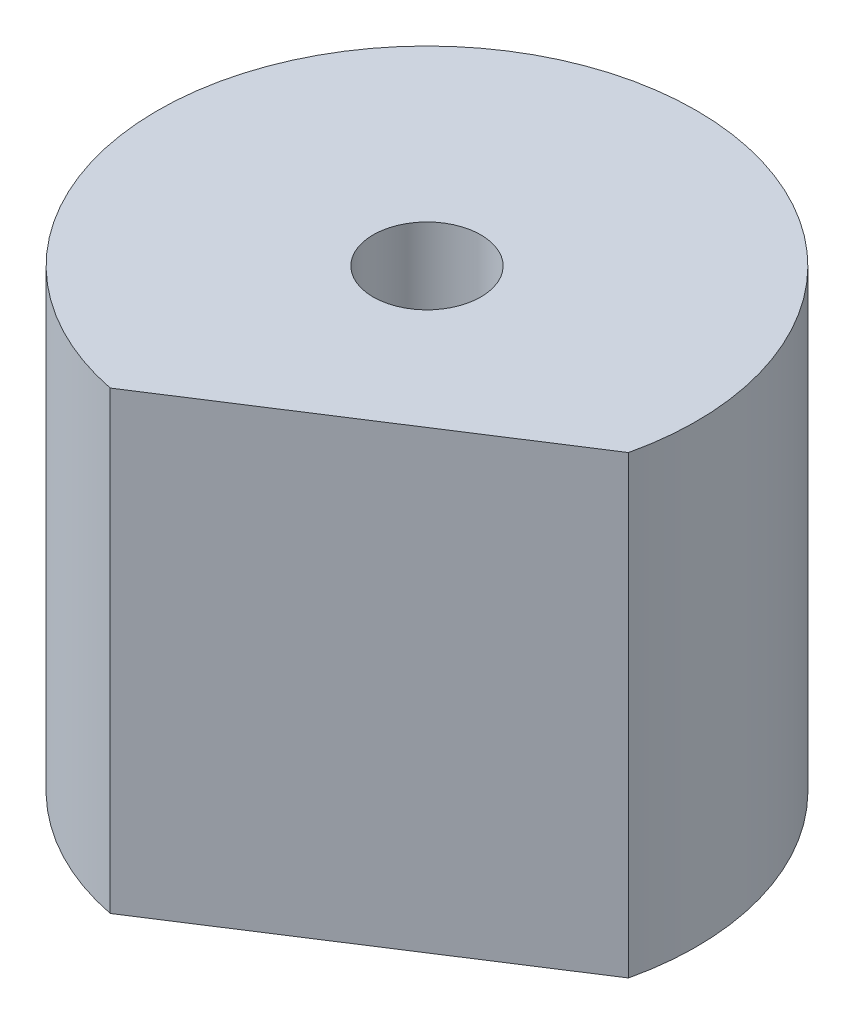
from build123d import *

# Parameters (mm, degrees)
SKETCH1_R               = 7.9375
SKETCH1_R_2             = 1.5875
BOSS_EXTRUDE1_DEPTH     = 13.4112
CUT_EXTRUDE1_DEPTH      = 18.489085109
CUT_EXTRUDE1_DEPTH_BACK = 18.489085109


with BuildPart() as part:
    # Sketch1 → Boss-Extrude1 (new body)
    with BuildSketch(Plane(origin=(0, 0, 0), x_dir=(1, 0, 0), z_dir=(0, 1, 0))):
        Circle(SKETCH1_R)
        Circle(SKETCH1_R_2, mode=Mode.SUBTRACT)
    extrude(amount=BOSS_EXTRUDE1_DEPTH)

    # Sketch2 → Cut-Extrude1 (cut, two sides: drawn at the far end of the back side and taken through both)
    with BuildSketch(Plane.XZ.offset(-CUT_EXTRUDE1_DEPTH_BACK)):
        Polygon((50.131920067, -25.566380741), (8.84885504, 1.07350014), (-2.66776804, 8.505154423), (-43.950833066, 35.145035304), (9.328928696, 117.711165357), (103.411681829, 56.999749312), align=None)
    extrude(amount=CUT_EXTRUDE1_DEPTH + CUT_EXTRUDE1_DEPTH_BACK, mode=Mode.SUBTRACT)


solid = part.part
